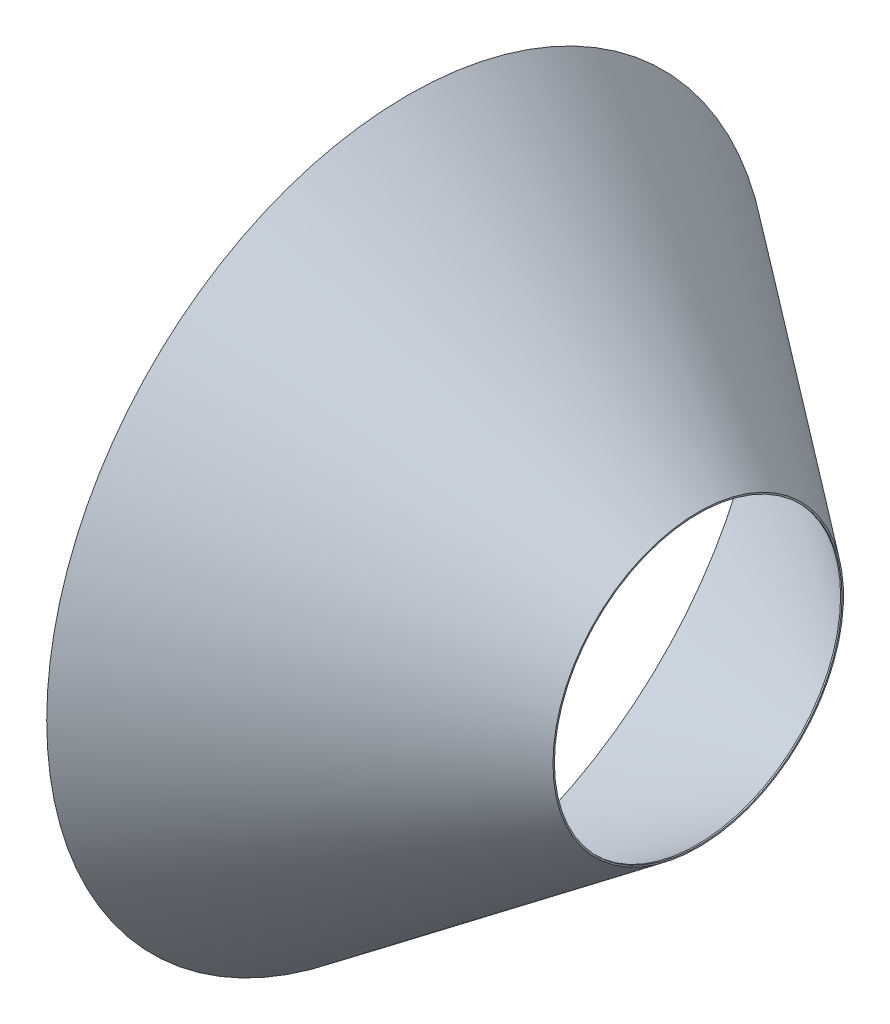
from build123d import *

# Parameters (mm, degrees)
SKETCH4_R          = 100
CUT_EXTRUDE2_DEPTH = 10
SKETCH5_R          = 250
CUT_EXTRUDE4_DEPTH = 1
SKETCH6_R          = 1.241785282
CUT_EXTRUDE5_DEPTH = 201


with BuildPart() as part:
    # Sketch1 → Revolve2 (revolve)
    with BuildSketch(Plane.XY):
        Polygon((0, 0), (0, 251), (202, 251), (202, 150), align=None)
        Polygon((201, 249.758214718), (201, 151), (0.5, 2.113861386), (1, 249.758214718), align=None, mode=Mode.SUBTRACT)
    revolve(axis=Axis((0, 251, 0), (1, 0, 0)))

    # Sketch4 → Cut-Extrude2 (cut)
    with BuildSketch(Plane(origin=(202, 0, 0), x_dir=(0, 0, -1), z_dir=(1, 0, 0))):
        with Locations((0, 251)):
            Circle(SKETCH4_R)
    extrude(amount=-CUT_EXTRUDE2_DEPTH, mode=Mode.SUBTRACT)

    # Sketch5 → Cut-Extrude4 (cut)
    with BuildSketch(Plane.ZY):
        with Locations((0, 251)):
            Circle(SKETCH5_R)
    extrude(amount=-CUT_EXTRUDE4_DEPTH, mode=Mode.SUBTRACT)

    # Sketch6 → Cut-Extrude5 (cut)
    with BuildSketch(Plane.ZY.offset(-1)):
        with Locations((0, 251)):
            Circle(SKETCH6_R)
    extrude(amount=-CUT_EXTRUDE5_DEPTH, mode=Mode.SUBTRACT)


solid = part.part
